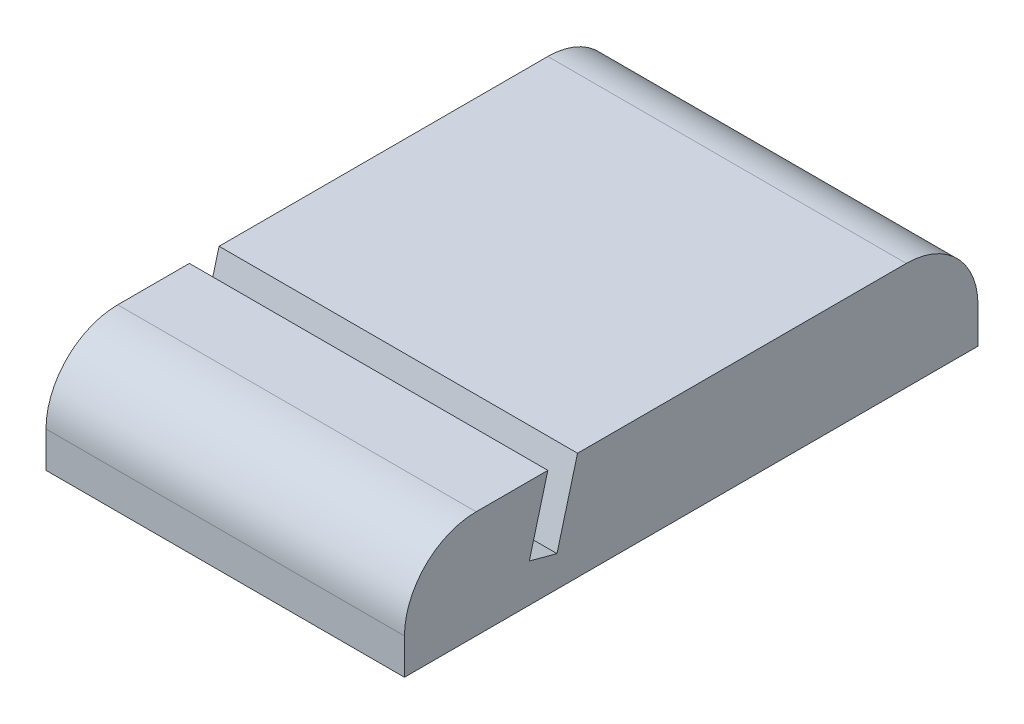
from build123d import *

# Parameters (mm, degrees)
BOSS_EXTRU_1_DEPTH = 50
CONG_1_R           = 10


with BuildPart() as part:
    # Esquisse1 → Boss.-Extru.1 (new body)
    with BuildSketch(Plane(origin=(0, 0, 0), x_dir=(0, 0, -1), z_dir=(1, 0, 0))):
        Polygon((-40, 0), (40, 0), (40, 15), (-15.858895278, 15), (-18.724487146, 4.305465557), (-22.588190451, 5.340741737), (-20, 15), (-40, 15), align=None)
    extrude(amount=BOSS_EXTRU_1_DEPTH)

    # Congé1
    cong_1_edges = [part.edges().sort_by_distance(p)[0] for p in [
        (25, 15, -40),
        (25, 15, 40),
    ]]
    fillet(cong_1_edges, radius=CONG_1_R)


solid = part.part
